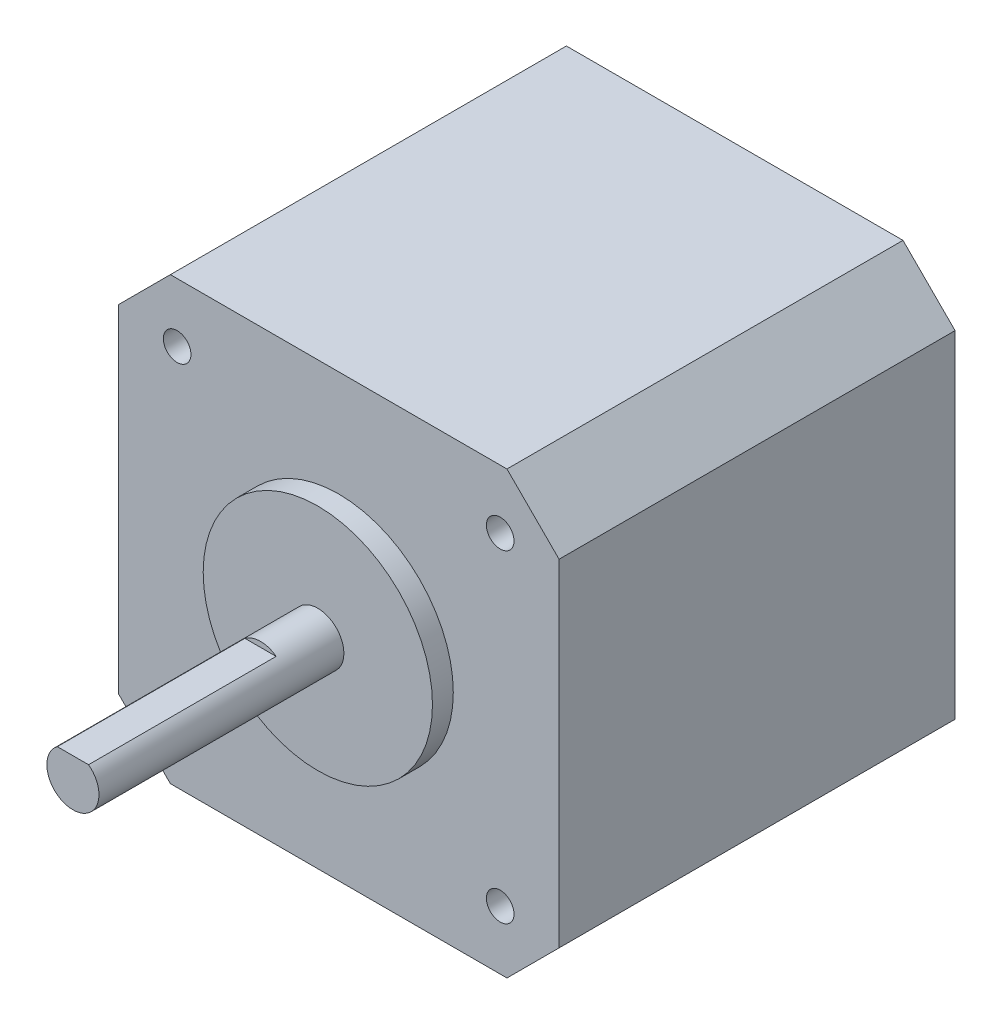
from build123d import *

# Parameters (mm, degrees)
EXTRUDE_1_DEPTH     = 38
M3X0_351_D          = 2.65
M3X0_351_DEPTH      = 7.75
M3X0_351_TIP        = 0.79614032
SKETCH_6_R          = 11
EXTRUDE_2_DEPTH     = 2
SKETCH_7_R          = 2.5
EXTRUDE_3_DEPTH     = 23.5
CUT_EXTRUDE_1_DEPTH = 18


with BuildPart() as part:
    # Эскиз1 → Бобышка-Вытянуть1 (new body)
    with BuildSketch(Plane.XY):
        Polygon((-21.15, 16.15), (-16.15, 21.15), (16.15, 21.15), (21.15, 16.15), (21.15, -16.15), (16.15, -21.15), (-16.15, -21.15), (-21.15, -16.15), align=None)
    extrude(amount=-EXTRUDE_1_DEPTH)

    # Отверстие обработанное метчиком M3x0.351
    with Locations(Plane.XY):
        with Locations((-15.5, 15.5), (15.5, 15.5), (15.5, -15.5), (-15.5, -15.5)):
            Hole(M3X0_351_D / 2, depth=M3X0_351_DEPTH)
            with Locations((0, 0, -(M3X0_351_DEPTH + M3X0_351_TIP / 2))):  # 118° drill point
                Cone(0, M3X0_351_D / 2, M3X0_351_TIP, mode=Mode.SUBTRACT)

    # Эскиз6 → Бобышка-Вытянуть2 (add)
    with BuildSketch(Plane.XY):
        Circle(SKETCH_6_R)
    extrude(amount=EXTRUDE_2_DEPTH)

    # Эскиз7 → Бобышка-Вытянуть3 (add)
    with BuildSketch(Plane.XY.offset(2)):
        Circle(SKETCH_7_R)
    extrude(amount=EXTRUDE_3_DEPTH)

    # Эскиз8 → Вырез-Вытянуть1 (cut)
    with BuildSketch(Plane.XY.offset(25.5)):
        with BuildLine():
            Line((-1.5, 2), (1.5, 2))
            ThreePointArc((1.5, 2), (0, 2.5), (-1.5, 2))
        make_face()
    extrude(amount=-CUT_EXTRUDE_1_DEPTH, mode=Mode.SUBTRACT)


solid = part.part
